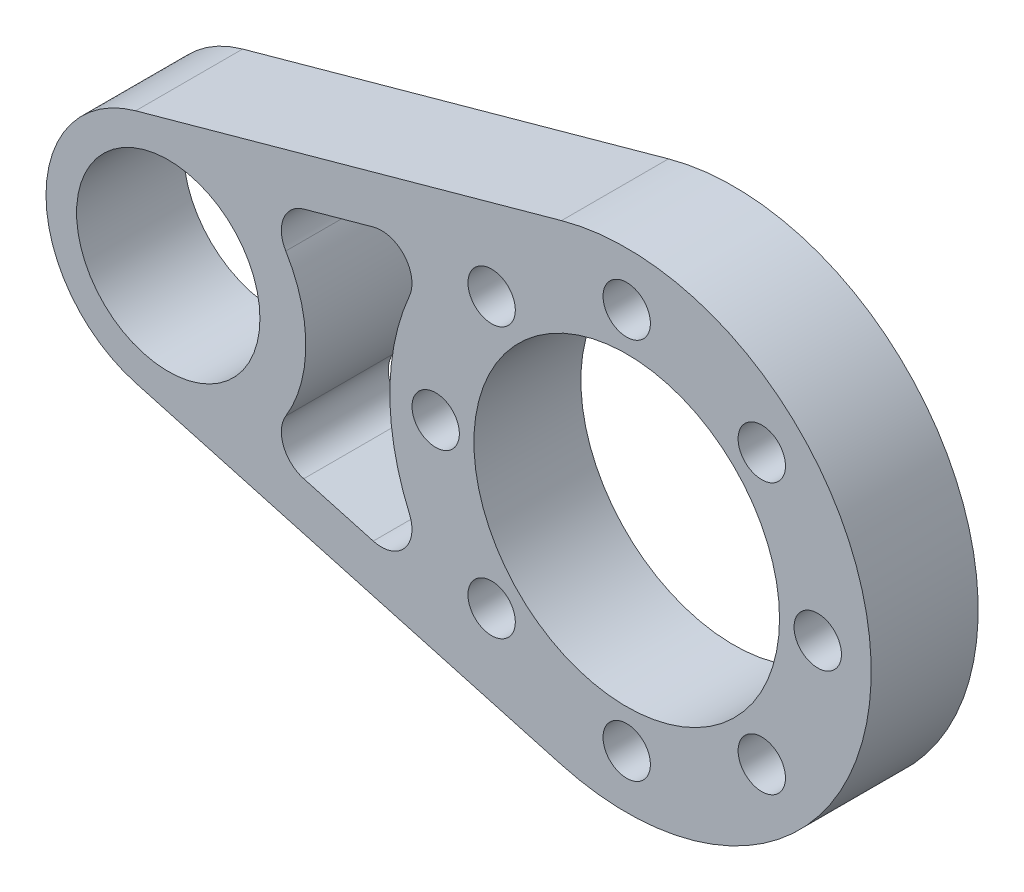
from build123d import *

# Parameters (mm, degrees)
SKETCH_1_R      = 6
SKETCH_1_R_2    = 10
SKETCH_1_R_3    = 1.55
EXTRUDE_1_DEPTH = 7
FILLET_1_R      = 2


with BuildPart() as part:
    # 草图1 → 凸台-拉伸1 (new body)
    with BuildSketch(Plane.XY):
        with BuildLine():
            Line((25.733333333, -15.420621114), (-2.133333333, -7.710310557))
            ThreePointArc((-2.133333333, -7.710310557), (-8, 0), (-2.133333333, 7.710310557))
            Line((-2.133333333, 7.710310557), (25.733333333, 15.420621114))
            ThreePointArc((25.733333333, 15.420621114), (46, 0), (25.733333333, -15.420621114))
        make_face()
        Circle(SKETCH_1_R, mode=Mode.SUBTRACT)
        with Locations((30, 0)):
            Circle(SKETCH_1_R_2, mode=Mode.SUBTRACT)
        with Locations((30, -12.5)):
            Circle(SKETCH_1_R_3, mode=Mode.SUBTRACT)
        with Locations((21.161165235, -8.838834765)):
            Circle(SKETCH_1_R_3, mode=Mode.SUBTRACT)
        with Locations((17.5, 0)):
            Circle(SKETCH_1_R_3, mode=Mode.SUBTRACT)
        with Locations((21.161165235, 8.838834765)):
            Circle(SKETCH_1_R_3, mode=Mode.SUBTRACT)
        with Locations((30, 12.5)):
            Circle(SKETCH_1_R_3, mode=Mode.SUBTRACT)
        with Locations((38.838834765, 8.838834765)):
            Circle(SKETCH_1_R_3, mode=Mode.SUBTRACT)
        with Locations((42.5, 0)):
            Circle(SKETCH_1_R_3, mode=Mode.SUBTRACT)
        with Locations((38.838834765, -8.838834765)):
            Circle(SKETCH_1_R_3, mode=Mode.SUBTRACT)
        with BuildLine():
            Line((5.879001779, -6.814494705), (18.398019367, -10.27832892))
            ThreePointArc((18.398019367, -10.27832892), (14.5, 0), (18.398019367, 10.27832892))
            Line((18.398019367, 10.27832892), (5.879001779, 6.814494705))
            ThreePointArc((5.879001779, 6.814494705), (9, 0), (5.879001779, -6.814494705))
        make_face(mode=Mode.SUBTRACT)
    extrude(amount=EXTRUDE_1_DEPTH)

    # 圆角1
    fillet_1_edges = [part.edges().sort_by_distance(p)[0] for p in [
        (5.879001779, 6.814494705, 3.5),
        (5.879001779, -6.814494705, 3.5),
        (18.398019367, -10.27832892, 3.5),
        (18.398019367, 10.27832892, 3.5),
    ]]
    fillet(fillet_1_edges, radius=FILLET_1_R)


solid = part.part
